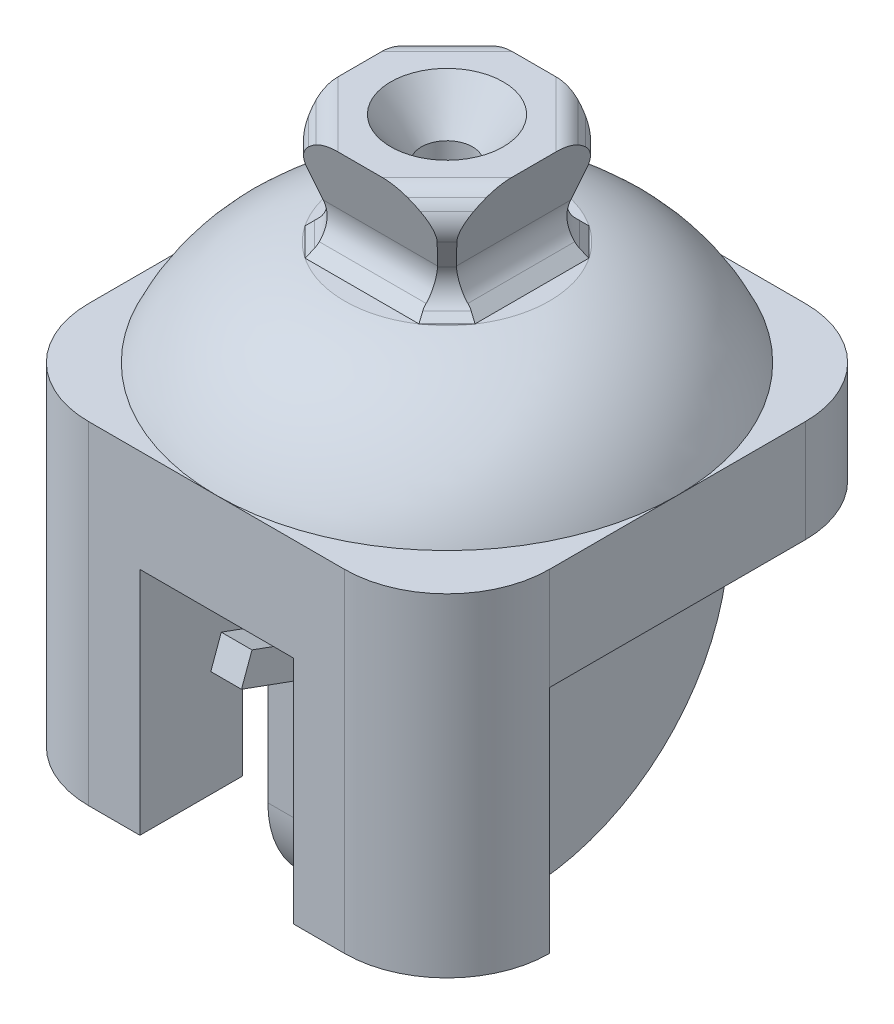
from build123d import *

# Parameters (mm, degrees)
SKETCH4_W           = 17
SKETCH4_H           = 11
BOSS_EXTRUDE2_DEPTH = 8.5
CUT_EXTRUDE1_DEPTH  = 13.5
CUT_EXTRUDE2_DEPTH  = 13.5
CUT_EXTRUDE3_DEPTH  = 13.5
CUT_EXTRUDE4_DEPTH  = 13.5
FILLET1_R           = 2
SKETCH16_W          = 45
SKETCH16_H          = 45
BOSS_EXTRUDE3_DEPTH = 10
SKETCH17_W          = 10
SKETCH17_H          = 35
BOSS_EXTRUDE4_DEPTH = 33.5
SKETCH18_W          = 15
SKETCH18_H          = 10
BOSS_EXTRUDE5_DEPTH = 22.5
SKETCH19_R          = 6
CUT_EXTRUDE5_DEPTH  = 28.5000001
FILLET3_R           = 10
FILLET4_R           = 20
SKETCH20_W          = 3
SKETCH20_H          = 8.5
BOSS_EXTRUDE6_DEPTH = 2.5
BOSS_EXTRUDE7_DEPTH = 3


with BuildPart() as part:
    # Sketch4 → Boss-Extrude2 (new body, symmetric)
    with BuildSketch(Plane.XY):
        Rectangle(SKETCH4_W, SKETCH4_H)
    extrude(amount=BOSS_EXTRUDE2_DEPTH, both=True)

    # Sketch5 → Cut-Extrude1 (cut, symmetric)
    with BuildSketch(Plane(origin=(0, 0, 0), x_dir=(0, 0, -1), z_dir=(1, 0, 0))):
        with BuildLine():
            Line((8.5, 5.5), (6.502509808, -1.291466653))
            ThreePointArc((6.502509808, -1.291466653), (6.473626767, -2.879228009), (7.259285969, -4.259285969))
            Line((7.259285969, -4.259285969), (8.5, -5.5))
            Line((8.5, -5.5), (8.5, 5.5))
        make_face()
        with BuildLine():
            Line((-8.5, -5.5), (-7.259285969, -4.259285969))
            ThreePointArc((-7.259285969, -4.259285969), (-6.473626767, -2.879228009), (-6.502509808, -1.291466653))
            Line((-6.502509808, -1.291466653), (-8.5, 5.5))
            Line((-8.5, 5.5), (-8.5, -5.5))
        make_face()
    extrude(amount=CUT_EXTRUDE1_DEPTH, both=True, mode=Mode.SUBTRACT)

    # Sketch7 → Cut-Extrude2 (cut, symmetric)
    with BuildSketch(Plane.XY):
        with BuildLine():
            Line((8.5, 5.5), (6.502538332, -1.291517059))
            ThreePointArc((6.502538332, -1.291517059), (6.473662442, -2.879270046), (7.259319467, -4.259319467))
            Line((7.259319467, -4.259319467), (8.5, -5.5))
            Line((8.5, -5.5), (8.5, 5.5))
        make_face()
        with BuildLine():
            Line((-8.5, -5.5), (-7.259319467, -4.259319467))
            ThreePointArc((-7.259319467, -4.259319467), (-6.473662442, -2.879270046), (-6.502538332, -1.291517059))
            Line((-6.502538332, -1.291517059), (-8.5, 5.5))
            Line((-8.5, 5.5), (-8.5, -5.5))
        make_face()
    extrude(amount=CUT_EXTRUDE2_DEPTH, both=True, mode=Mode.SUBTRACT)

    # Sketch11 → Cut-Extrude3 (cut, symmetric)
    with BuildSketch(Plane(origin=(0, 0, 0), x_dir=(0.707106781, 0, -0.707106781), z_dir=(0.707106781, 0, 0.707106781))):
        with BuildLine():
            Line((10, -5.5), (9.159523089, -4.659523089))
            ThreePointArc((9.159523089, -4.659523089), (8.341069319, -3.136306549), (8.499291869, -1.414382965))
            Line((8.499291869, -1.414382965), (9.693462893, 1.541294037))
            ThreePointArc((9.693462893, 1.541294037), (9.908907559, 2.799328578), (9.581873492, 4.033069244))
            ThreePointArc((9.581873492, 4.033069244), (9.013209006, 4.854851227), (8.25, 5.5))
            Line((8.25, 5.5), (14, 5.5))
            Line((14, 5.5), (14, -5.5))
            Line((14, -5.5), (10, -5.5))
        make_face()
        with BuildLine():
            Line((-14, 5.5), (-8.25, 5.5))
            ThreePointArc((-8.25, 5.5), (-9.013209006, 4.854851227), (-9.581873492, 4.033069244))
            ThreePointArc((-9.581873492, 4.033069244), (-9.908907559, 2.799328578), (-9.693462893, 1.541294037))
            Line((-9.693462893, 1.541294037), (-8.499291869, -1.414382965))
            ThreePointArc((-8.499291869, -1.414382965), (-8.341069319, -3.136306549), (-9.159523089, -4.659523089))
            Line((-9.159523089, -4.659523089), (-10, -5.5))
            Line((-10, -5.5), (-14, -5.5))
            Line((-14, -5.5), (-14, 5.5))
        make_face()
    extrude(amount=CUT_EXTRUDE3_DEPTH, both=True, mode=Mode.SUBTRACT)

    # Sketch12 → Cut-Extrude4 (cut, symmetric)
    with BuildSketch(Plane(origin=(0, 0, 0), x_dir=(-0.707106781, 0, -0.707106781), z_dir=(0.707106781, 0, -0.707106781))):
        with BuildLine():
            Line((10, -5.5), (9.159523089, -4.659523089))
            ThreePointArc((9.159523089, -4.659523089), (8.341069319, -3.136306549), (8.499291869, -1.414382965))
            Line((8.499291869, -1.414382965), (9.693462893, 1.541294037))
            ThreePointArc((9.693462893, 1.541294037), (9.908907559, 2.799328578), (9.581873492, 4.033069244))
            ThreePointArc((9.581873492, 4.033069244), (9.013209006, 4.854851227), (8.25, 5.5))
            Line((8.25, 5.5), (14, 5.5))
            Line((14, 5.5), (14, -5.5))
            Line((14, -5.5), (10, -5.5))
        make_face()
        with BuildLine():
            Line((-14, 5.5), (-8.25, 5.5))
            ThreePointArc((-8.25, 5.5), (-9.013209006, 4.854851227), (-9.581873492, 4.033069244))
            ThreePointArc((-9.581873492, 4.033069244), (-9.908907559, 2.799328578), (-9.693462893, 1.541294037))
            Line((-9.693462893, 1.541294037), (-8.499291869, -1.414382965))
            ThreePointArc((-8.499291869, -1.414382965), (-8.341069319, -3.136306549), (-9.159523089, -4.659523089))
            Line((-9.159523089, -4.659523089), (-10, -5.5))
            Line((-10, -5.5), (-14, -5.5))
            Line((-14, -5.5), (-14, 5.5))
        make_face()
    extrude(amount=CUT_EXTRUDE4_DEPTH, both=True, mode=Mode.SUBTRACT)

    # Sketch14 → Cut-Revolve1 (revolve, cut)
    with BuildSketch(Plane.XY):
        Polygon((0, 5.5), (5.5, 5.5), (2.5, 1.5), (2.5, -5.5), (0, -5.5), align=None)
    revolve(axis=Axis((0, -5.5, 0), (0, 1, 0)), mode=Mode.SUBTRACT)

    # Fillet1
    fillet1_edges = [part.edges().sort_by_distance(p)[0] for p in [
        (5.833630945, 5.5, -5.833630945),
        (-5.833630945, 5.5, -5.833630945),
        (-5.833630945, 5.5, 5.833630945),
        (5.833630945, 5.5, 5.833630945),
    ]]
    fillet(fillet1_edges, radius=FILLET1_R)

    # Sketch15 → Revolve1 (revolve)
    with BuildSketch(Plane(origin=(0, 0, 0), x_dir=(0, 0, -1), z_dir=(1, 0, 0))):
        with BuildLine():
            Line((0, -15.5), (22.5, -15.5))
            ThreePointArc((22.5, -15.5), (17.455904629, -8.920713416), (9.9979998, -5.3))
            Line((9.9979998, -5.3), (0, -5.3))
            Line((0, -5.3), (0, -5.5))
            Line((0, -5.5), (0, -15.5))
        make_face()
    revolve(axis=Axis((0, -5.5, 0), (0, -1, 0)))

    # Sketch16 → Boss-Extrude3 (add)
    with BuildSketch(Plane.XZ.offset(15.5)):
        Rectangle(SKETCH16_W, SKETCH16_H)
    extrude(amount=BOSS_EXTRUDE3_DEPTH)

    # Sketch17 → Boss-Extrude4 (add)
    with BuildSketch(Plane.XZ.offset(25.5)):
        with Locations((0, -5)):
            Rectangle(SKETCH17_W, SKETCH17_H)
    extrude(amount=BOSS_EXTRUDE4_DEPTH)

    # Sketch18 → Boss-Extrude5 (add)
    with BuildSketch(Plane.XZ.offset(25.5)):
        with Locations((15, 17.5)):
            Rectangle(SKETCH18_W, SKETCH18_H)
        with Locations((-15, 17.5)):
            Rectangle(SKETCH18_W, SKETCH18_H)
    extrude(amount=BOSS_EXTRUDE5_DEPTH)

    # Sketch19 → Cut-Extrude5 (cut, through all)
    with BuildSketch(Plane(origin=(5, 0, 0), x_dir=(0, 0, -1), z_dir=(1, 0, 0))):
        with Locations((-3.5, -48)):
            Circle(SKETCH19_R)
    extrude(amount=-CUT_EXTRUDE5_DEPTH, mode=Mode.SUBTRACT)

    # Fillet3
    fillet3_edges = [part.edges().sort_by_distance(p)[0] for p in [
        (-22.5, -31.75, 22.5),
        (22.5, -31.75, 22.5),
        (-22.5, -20.5, -22.5),
        (22.5, -20.5, -22.5),
        (0, -59, 12.5),
    ]]
    fillet(fillet3_edges, radius=FILLET3_R)

    # Fillet4
    fillet4_edges = [part.edges().sort_by_distance(p)[0] for p in [
        (0, -59, -22.5),
    ]]
    fillet(fillet4_edges, radius=FILLET4_R)

    # Sketch20 → Boss-Extrude6 (add)
    with BuildSketch(Plane.XY.offset(12.5)):
        with Locations((0, -29.75)):
            Rectangle(SKETCH20_W, SKETCH20_H)
    extrude(amount=BOSS_EXTRUDE6_DEPTH)

    # Sketch21 → Boss-Extrude7 (add)
    with BuildSketch(Plane(origin=(1.5, 0, 0), x_dir=(0, 0, -1), z_dir=(1, 0, 0))):
        Polygon((-15, -30.807466683), (-15, -34), (-21.577848346, -31.605858997), (-20.551787916, -28.786781134), align=None)
    extrude(amount=-BOSS_EXTRUDE7_DEPTH)


solid = part.part
